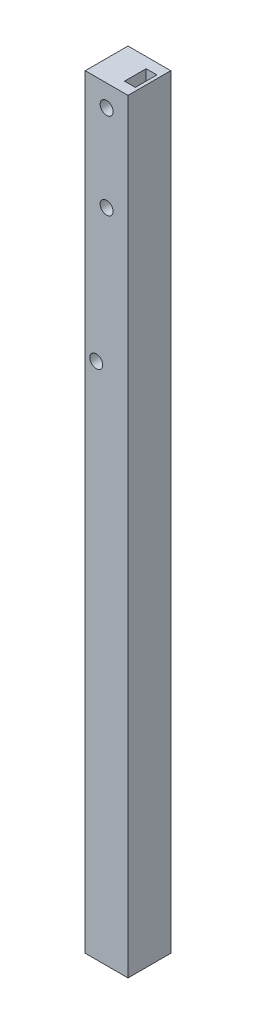
from build123d import *

# Parameters (mm, degrees)
SKETCH_1_W         = 9.9
SKETCH_1_H         = 9.9
SKETCH_1_W_2       = 2.5
SKETCH_1_H_2       = 5
EXTRUDE_1_DEPTH    = 177
SKETCH2_R          = 1.5
CUT_EXTRUDE2_DEPTH = 10.9


with BuildPart() as part:
    # Эскиз1 → Бобышка-Вытянуть1 (new body)
    with BuildSketch(Plane(origin=(0, 0, 0), x_dir=(1, 0, 0), z_dir=(0, 1, 0))):
        with Locations((-0.744758221, -0.10825854)):
            Rectangle(SKETCH_1_W, SKETCH_1_H)
        with Locations((2.205241779, -0.10825854)):
            Rectangle(SKETCH_1_W_2, SKETCH_1_H_2, mode=Mode.SUBTRACT)
    extrude(amount=EXTRUDE_1_DEPTH)

    # Sketch2 → Cut-Extrude2 (cut, through all)
    with BuildSketch(Plane(origin=(0, 0, -4.84174146), x_dir=(-1, 0, 0), z_dir=(0, 0, -1))):
        with Locations((0.744758221, 172)):
            Circle(SKETCH2_R)
        with Locations((3.144758221, 120)):
            Circle(SKETCH2_R)
        with Locations((0.744758221, 152)):
            Circle(SKETCH2_R)
    extrude(amount=-CUT_EXTRUDE2_DEPTH, mode=Mode.SUBTRACT)


solid = part.part
